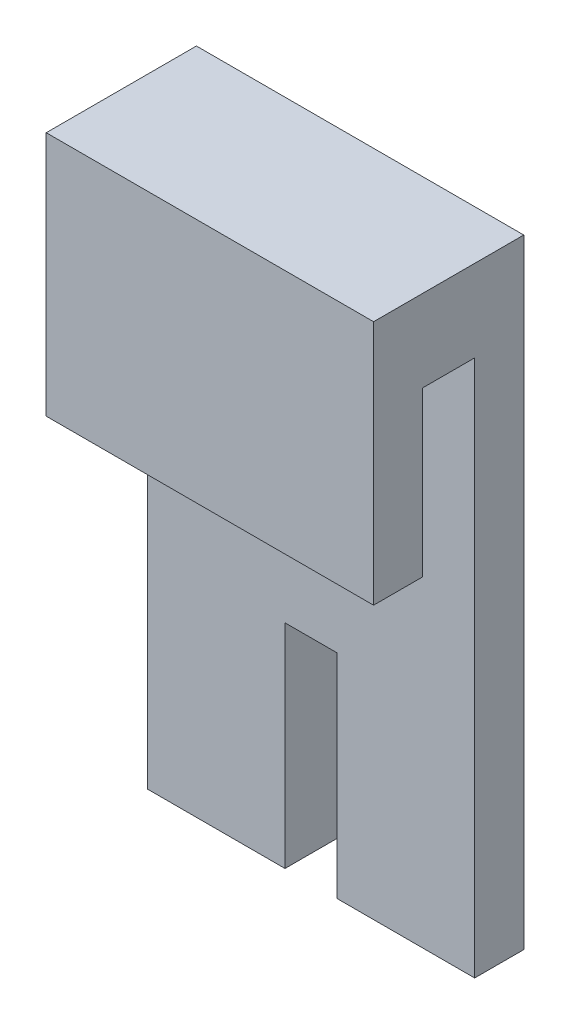
from build123d import *

# Parameters (mm, degrees)
BOSS_EXTRUDE1_DEPTH = 20
BOSS_EXTRUDE2_DEPTH = 5
SKETCH3_W           = 3.175
SKETCH3_H           = 13
CUT_EXTRUDE1_DEPTH  = 3


with BuildPart() as part:
    # Sketch1 → Boss-Extrude1 (new body)
    with BuildSketch(Plane(origin=(0, 0, 0), x_dir=(0, 0, -1), z_dir=(1, 0, 0))):
        Polygon((0, 0), (3, 0), (3, 10), (6.175, 10), (6.175, -22.812), (9.175, -22.812), (9.175, 15), (0, 15), align=None)
    extrude(amount=BOSS_EXTRUDE1_DEPTH)

    # Sketch2 → Boss-Extrude2 (add)
    with BuildSketch(Plane(origin=(0, 0, -9.175), x_dir=(-1, 0, 0), z_dir=(0, 0, -1))):
        Polygon((-11.5875, -22.812), (-11.5875, -9.812), (-8.4125, -9.812), (-8.4125, -22.812), (-5.4125, -22.812), (-5.4125, -6.812), (-14.5875, -6.812), (-14.5875, -22.812), align=None)
    extrude(amount=BOSS_EXTRUDE2_DEPTH)

    # Sketch3 → Cut-Extrude1 (cut)
    with BuildSketch(Plane(origin=(0, 0, -9.175), x_dir=(-1, 0, 0), z_dir=(0, 0, -1))):
        with Locations((-10, -16.312)):
            Rectangle(SKETCH3_W, SKETCH3_H)
    extrude(amount=-CUT_EXTRUDE1_DEPTH, mode=Mode.SUBTRACT)


solid = part.part
